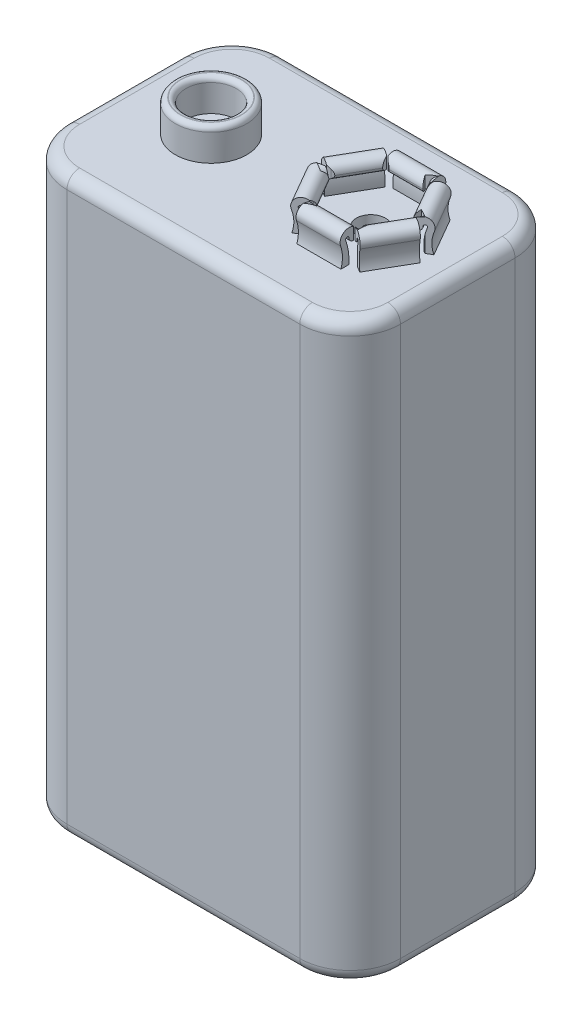
from build123d import *

# Parameters (mm, degrees)
EXTRUDE1_DEPTH     = 45.65
FILLET1_R          = 1
SKETCH2_R          = 1.15
CUT_EXTRUDE1_DEPTH = 1
SKETCH3_R          = 2.84
SKETCH3_R_2        = 2
EXTRUDE2_DEPTH     = 2.54
FILLET2_R          = 0.4
SKETCH4_W          = 3.5
SKETCH4_H          = 1.4
EXTRUDE3_DEPTH     = 2.54
CUT_EXTRUDE2_DEPTH = 4
CUT_EXTRUDE3_DEPTH = 4
CIRPATTERN2_COUNT  = 6


with BuildPart() as part:
    # Sketch1 → Extrude1 (new body)
    with BuildSketch(Plane(origin=(0, 0, 0), x_dir=(1, 0, 0), z_dir=(0, 1, 0))):
        with BuildLine():
            Line((-9.25, 8.55), (9.25, 8.55))
            ThreePointArc((9.25, 8.55), (12.078427125, 7.378427125), (13.25, 4.55))
            Line((13.25, 4.55), (13.25, -4.55))
            ThreePointArc((13.25, -4.55), (12.078427125, -7.378427125), (9.25, -8.55))
            Line((9.25, -8.55), (-9.25, -8.55))
            ThreePointArc((-9.25, -8.55), (-12.078427125, -7.378427125), (-13.25, -4.55))
            Line((-13.25, -4.55), (-13.25, 4.55))
            ThreePointArc((-13.25, 4.55), (-12.078427125, 7.378427125), (-9.25, 8.55))
        make_face()
    extrude(amount=EXTRUDE1_DEPTH)

    # Fillet1
    fillet1_edges = [part.edges().sort_by_distance(p)[0] for p in [
        (-12.078427125, 45.65, -7.378427125),
        (-13.25, 45.65, 0),
        (-12.078427125, 45.65, 7.378427125),
        (0, 45.65, 8.55),
        (12.078427125, 45.65, 7.378427125),
        (13.25, 45.65, 0),
        (12.078427125, 45.65, -7.378427125),
        (13.25, 0, 0),
        (0, 45.65, -8.55),
        (12.078427125, 0, 7.378427125),
        (0, 0, 8.55),
        (-12.078427125, 0, 7.378427125),
        (-13.25, 0, 0),
        (-12.078427125, 0, -7.378427125),
        (0, 0, -8.55),
        (12.078427125, 0, -7.378427125),
    ]]
    fillet(fillet1_edges, radius=FILLET1_R)

    # Sketch2 → Cut-Extrude1 (cut)
    with BuildSketch(Plane(origin=(0, 45.65, 0), x_dir=(-1, 0, 0), z_dir=(0, 1, 0))):
        with Locations(Location((6.35, 0, 0), (0, 0, 90))):  # turned: the seam where the file's is
            Circle(SKETCH2_R)
        with Locations(Location((-6.35, 0, 0), (0, 0, 90))):  # turned: the seam where the file's is
            Circle(SKETCH2_R)
    extrude(amount=-CUT_EXTRUDE1_DEPTH, mode=Mode.SUBTRACT)

    # Sketch3 → Extrude2 (add)
    with BuildSketch(Plane(origin=(0, 45.65, 0), x_dir=(-1, 0, 0), z_dir=(0, 1, 0))):
        with Locations(Location((6.35, 0, 0), (0, 0, 270))):  # turned: the seam where the file's is
            Circle(SKETCH3_R)
        with Locations(Location((6.35, 0, 0), (0, 0, 90))):  # turned: the seam where the file's is
            Circle(SKETCH3_R_2, mode=Mode.SUBTRACT)
    extrude(amount=EXTRUDE2_DEPTH)

    # Fillet2
    fillet2_edges = [part.edges().sort_by_distance(p)[0] for p in [
        (-6.35, 48.19, 2.84),
        (-6.35, 48.19, -2),
    ]]
    fillet(fillet2_edges, radius=FILLET2_R)

    # Sketch4 → Extrude3 (add)
    with BuildSketch(Plane(origin=(0, 45.65, 0), x_dir=(-1, 0, 0), z_dir=(0, 1, 0))):
        with Locations((-6.35, -3.5)):
            Rectangle(SKETCH4_W, SKETCH4_H)
    extrude3 = extrude(amount=EXTRUDE3_DEPTH)

    # Sketch5 → Cut-Extrude2 (cut)
    with BuildSketch(Plane(origin=(8.1, 0, 0), x_dir=(0, 0, -1), z_dir=(1, 0, 0))):
        with BuildLine():
            Line((4.13400445, 45.65), (4.55, 45.65))
            Line((4.55, 45.65), (4.55, 48.403159162))
            Line((4.55, 48.403159162), (2.544765199, 48.403159162))
            Line((2.544765199, 48.403159162), (2.544765199, 45.65))
            Line((2.544765199, 45.65), (3.5, 45.65))
            ThreePointArc((3.5, 45.65), (3.535730788, 46.560835661), (3.754944335, 47.445620218))
            ThreePointArc((3.754944335, 47.445620218), (3.65385849, 47.619389121), (3.5, 47.49))
            ThreePointArc((3.5, 47.49), (3.15, 47.14), (2.8, 47.49))
            ThreePointArc((2.8, 47.49), (3.620027609, 48.179632781), (4.158838209, 47.253500074))
            ThreePointArc((4.158838209, 47.253500074), (4.013267709, 46.453812217), (4.13400445, 45.65))
        make_face()
    cut_extrude2 = extrude(amount=-CUT_EXTRUDE2_DEPTH, mode=Mode.SUBTRACT)

    # Sketch6 → Cut-Extrude3 (cut)
    with BuildSketch(Plane(origin=(0, 45.65, 0), x_dir=(-1, 0, 0), z_dir=(0, 1, 0))):
        Polygon((-7.781645023, -2.8), (-8.1, -2.8), (-8.1, -3.115078907), align=None)
        Polygon((-4.6, -2.8), (-4.918354977, -2.8), (-4.6, -3.115078907), align=None)
    cut_extrude3 = extrude(amount=CUT_EXTRUDE3_DEPTH, mode=Mode.SUBTRACT)

    # CirPattern2: Extrude3, Cut-Extrude2, Cut-Extrude3 ×6 about axis
    cirpattern2_axis = Axis((6.35, 0, 0), (0, 1, 0))
    add([extrude3.rotate(cirpattern2_axis, i * 360 / CIRPATTERN2_COUNT) for i in range(1, CIRPATTERN2_COUNT)])
    add([cut_extrude2.rotate(cirpattern2_axis, i * 360 / CIRPATTERN2_COUNT) for i in range(1, CIRPATTERN2_COUNT)], mode=Mode.SUBTRACT)
    add([cut_extrude3.rotate(cirpattern2_axis, i * 360 / CIRPATTERN2_COUNT) for i in range(1, CIRPATTERN2_COUNT)], mode=Mode.SUBTRACT)


solid = part.part
